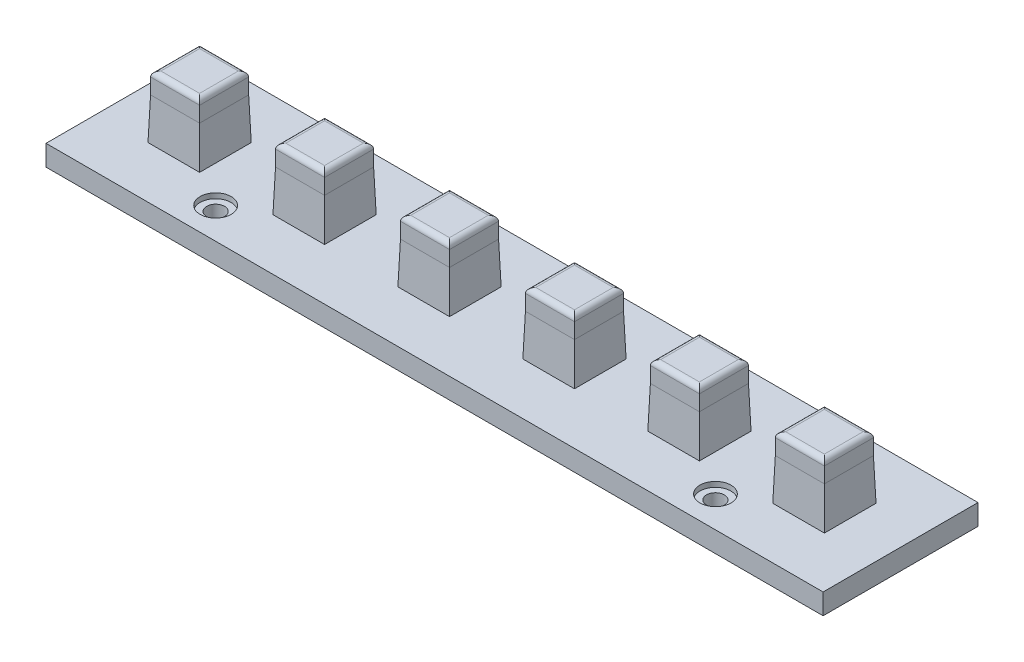
from build123d import *

# Parameters (mm, degrees)
SKETCH1_W                = 150.5
SKETCH1_H                = 30
SKETCH1_W_2              = 9.5
SKETCH1_H_2              = 9.5
BOSS_EXTRUDE1_DEPTH      = 4
SKETCH2_W                = 9.5
SKETCH2_H                = 9.5
BOSS_EXTRUDE2_DEPTH      = 12
BOSS_EXTRUDE2_DEPTH_BACK = 4
FILLET1_R                = 1
CHAMFER1_SIZE            = 0.25
CHAMFER1_SIZE2           = 8
SKETCH3_R                = 1.725
CUT_EXTRUDE1_DEPTH       = 5
SKETCH4_R                = 3
CUT_EXTRUDE2_DEPTH       = 1


with BuildPart() as part:
    # Sketch1 → Boss-Extrude1 (new body)
    with BuildSketch(Plane(origin=(0, 0, 0), x_dir=(1, 0, 0), z_dir=(0, 1, 0))):
        with Locations((75.25, 15)):
            Rectangle(SKETCH1_W, SKETCH1_H)
        with Locations((14.75, 15)):
            Rectangle(SKETCH1_W_2, SKETCH1_H_2, mode=Mode.SUBTRACT)
        with Locations((38.95, 15)):
            Rectangle(SKETCH1_W_2, SKETCH1_H_2, mode=Mode.SUBTRACT)
        with Locations((63.15, 15)):
            Rectangle(SKETCH1_W_2, SKETCH1_H_2, mode=Mode.SUBTRACT)
        with Locations((87.35, 15)):
            Rectangle(SKETCH1_W_2, SKETCH1_H_2, mode=Mode.SUBTRACT)
        with Locations((111.55, 15)):
            Rectangle(SKETCH1_W_2, SKETCH1_H_2, mode=Mode.SUBTRACT)
        with Locations((135.75, 15)):
            Rectangle(SKETCH1_W_2, SKETCH1_H_2, mode=Mode.SUBTRACT)
    extrude(amount=BOSS_EXTRUDE1_DEPTH)

    # Sketch2 → Boss-Extrude2 (add, two sides)
    with BuildSketch(Plane(origin=(0, 4, 0), x_dir=(1, 0, 0), z_dir=(0, 1, 0))) as boss_extrude2_sk:
        with Locations((14.75, 15)):
            Rectangle(SKETCH2_W, SKETCH2_H)
        with Locations((38.95, 15)):
            Rectangle(SKETCH2_W, SKETCH2_H)
        with Locations((63.15, 15)):
            Rectangle(SKETCH2_W, SKETCH2_H)
        with Locations((87.35, 15)):
            Rectangle(SKETCH2_W, SKETCH2_H)
        with Locations((111.55, 15)):
            Rectangle(SKETCH2_W, SKETCH2_H)
        with Locations((135.75, 15)):
            Rectangle(SKETCH2_W, SKETCH2_H)
    extrude(amount=BOSS_EXTRUDE2_DEPTH)
    extrude(boss_extrude2_sk.sketch, amount=-BOSS_EXTRUDE2_DEPTH_BACK)

    # Fillet1
    fillet1_edges = [part.edges().sort_by_distance(p)[0] for p in [
        (10, 16, -15),
        (14.75, 16, -10.25),
        (19.5, 16, -15),
        (14.75, 16, -19.75),
        (34.2, 16, -15),
        (38.95, 16, -10.25),
        (43.7, 16, -15),
        (38.95, 16, -19.75),
        (58.4, 16, -15),
        (63.15, 16, -10.25),
        (67.9, 16, -15),
        (63.15, 16, -19.75),
        (82.6, 16, -15),
        (87.35, 16, -10.25),
        (92.1, 16, -15),
        (87.35, 16, -19.75),
        (106.8, 16, -15),
        (111.55, 16, -10.25),
        (116.3, 16, -15),
        (111.55, 16, -19.75),
        (140.5, 16, -15),
        (135.75, 16, -19.75),
        (131, 16, -15),
        (135.75, 16, -10.25),
    ]]
    fillet(fillet1_edges, radius=FILLET1_R)

    # Chamfer1
    chamfer1_edges = [part.edges().sort_by_distance(p)[0] for p in [
        (10, 4, -15),
        (14.75, 4, -10.25),
        (19.5, 4, -15),
        (14.75, 4, -19.75),
        (58.4, 4, -15),
        (63.15, 4, -10.25),
        (67.9, 4, -15),
        (63.15, 4, -19.75),
        (34.2, 4, -15),
        (38.95, 4, -10.25),
        (43.7, 4, -15),
        (38.95, 4, -19.75),
        (82.6, 4, -15),
        (87.35, 4, -10.25),
        (92.1, 4, -15),
        (87.35, 4, -19.75),
        (106.8, 4, -15),
        (111.55, 4, -10.25),
        (116.3, 4, -15),
        (111.55, 4, -19.75),
        (140.5, 4, -15),
        (135.75, 4, -19.75),
        (131, 4, -15),
        (135.75, 4, -10.25),
    ]]
    chamfer1_side = [part.faces().sort_by_distance(p)[0] for p in [
        (75.25, 4, -15),
    ]]
    chamfer(chamfer1_edges, length=CHAMFER1_SIZE, length2=CHAMFER1_SIZE2, reference=chamfer1_side[0])

    # Sketch3 → Cut-Extrude1 (cut, through all)
    with BuildSketch(Plane(origin=(0, 4, 0), x_dir=(1, 0, 0), z_dir=(0, 1, 0))):
        with Locations((26.85, 6)):
            Circle(SKETCH3_R)
        with Locations((26.85, 24)):
            Circle(SKETCH3_R)
        with Locations((123.65, 6)):
            Circle(SKETCH3_R)
        with Locations((123.65, 24)):
            Circle(SKETCH3_R)
    extrude(amount=-CUT_EXTRUDE1_DEPTH, mode=Mode.SUBTRACT)

    # Sketch4 → Cut-Extrude2 (cut)
    with BuildSketch(Plane(origin=(0, 4, 0), x_dir=(1, 0, 0), z_dir=(0, 1, 0))):
        with Locations((26.85, 24)):
            Circle(SKETCH4_R)
        with Locations((26.85, 6)):
            Circle(SKETCH4_R)
        with Locations((123.65, 6)):
            Circle(SKETCH4_R)
        with Locations((123.65, 24)):
            Circle(SKETCH4_R)
    extrude(amount=-CUT_EXTRUDE2_DEPTH, mode=Mode.SUBTRACT)


solid = part.part
